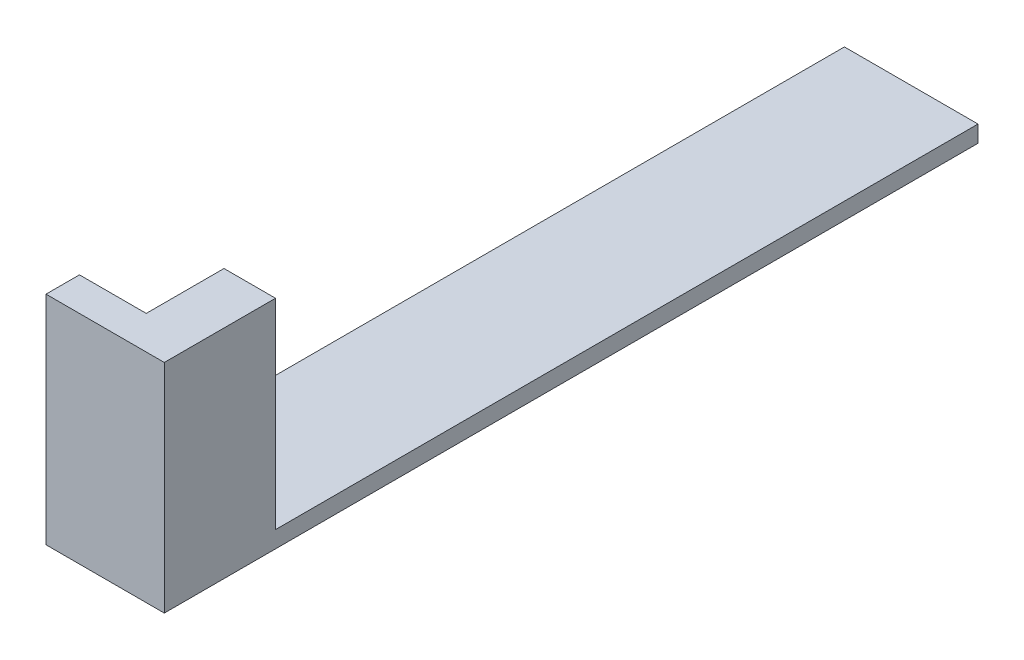
from build123d import *

# Parameters (mm, degrees)
SCHIZZO1_W                   = 8
SCHIZZO1_H                   = 42.07
ESTRUSIONE_ESTRUSIONE1_DEPTH = 1
SCHIZZO2_W                   = 3.084803914
SCHIZZO2_H                   = 1
ESTRUSIONE_ESTRUSIONE2_DEPTH = 4.66
SCHIZZO3_W                   = 3.084803914
SCHIZZO3_H                   = 1
ESTRUSIONE_ESTRUSIONE3_DEPTH = 2
SCHIZZO4_W                   = 2.003143521
SCHIZZO4_H                   = 1
ESTRUSIONE_ESTRUSIONE4_DEPTH = 4
SCHIZZO5_W                   = 7.084803914
SCHIZZO5_H                   = 2.003143521
ESTRUSIONE_ESTRUSIONE5_DEPTH = 12
SCHIZZO7_W                   = 3.084803914
SCHIZZO7_H                   = 4.656856479
ESTRUSIONE_ESTRUSIONE7_DEPTH = 12


with BuildPart() as part:
    # Schizzo1 → Estrusione-Estrusione1 (new body)
    with BuildSketch(Plane(origin=(0, 0, 0), x_dir=(1, 0, 0), z_dir=(0, 1, 0))):
        with Locations((4, 21.035)):
            Rectangle(SCHIZZO1_W, SCHIZZO1_H)
    extrude(amount=ESTRUSIONE_ESTRUSIONE1_DEPTH)

    # Schizzo2 → Estrusione-Estrusione2 (add)
    with BuildSketch(Plane.XY):
        with Locations((6.457598043, 0.5)):
            Rectangle(SCHIZZO2_W, SCHIZZO2_H)
    extrude(amount=ESTRUSIONE_ESTRUSIONE2_DEPTH)

    # Schizzo3 → Estrusione-Estrusione3 (add)
    with BuildSketch(Plane.XY.offset(4.66)):
        with Locations((6.457598043, 0.5)):
            Rectangle(SCHIZZO3_W, SCHIZZO3_H)
    extrude(amount=ESTRUSIONE_ESTRUSIONE3_DEPTH)

    # Schizzo4 → Estrusione-Estrusione4 (add)
    with BuildSketch(Plane.ZY.offset(-4.915196086)):
        with Locations((5.65842824, 0.5)):
            Rectangle(SCHIZZO4_W, SCHIZZO4_H)
    extrude(amount=ESTRUSIONE_ESTRUSIONE4_DEPTH)

    # Schizzo5 → Estrusione-Estrusione5 (add)
    with BuildSketch(Plane(origin=(0, 1, 0), x_dir=(1, 0, 0), z_dir=(0, 1, 0))):
        with Locations((4.457598043, -5.65842824)):
            Rectangle(SCHIZZO5_W, SCHIZZO5_H)
    extrude(amount=ESTRUSIONE_ESTRUSIONE5_DEPTH)

    # Schizzo7 → Estrusione-Estrusione7 (add)
    with BuildSketch(Plane(origin=(0, 1, 0), x_dir=(1, 0, 0), z_dir=(0, 1, 0))):
        with Locations((6.457598043, -2.328428239)):
            Rectangle(SCHIZZO7_W, SCHIZZO7_H)
    extrude(amount=ESTRUSIONE_ESTRUSIONE7_DEPTH)


solid = part.part
